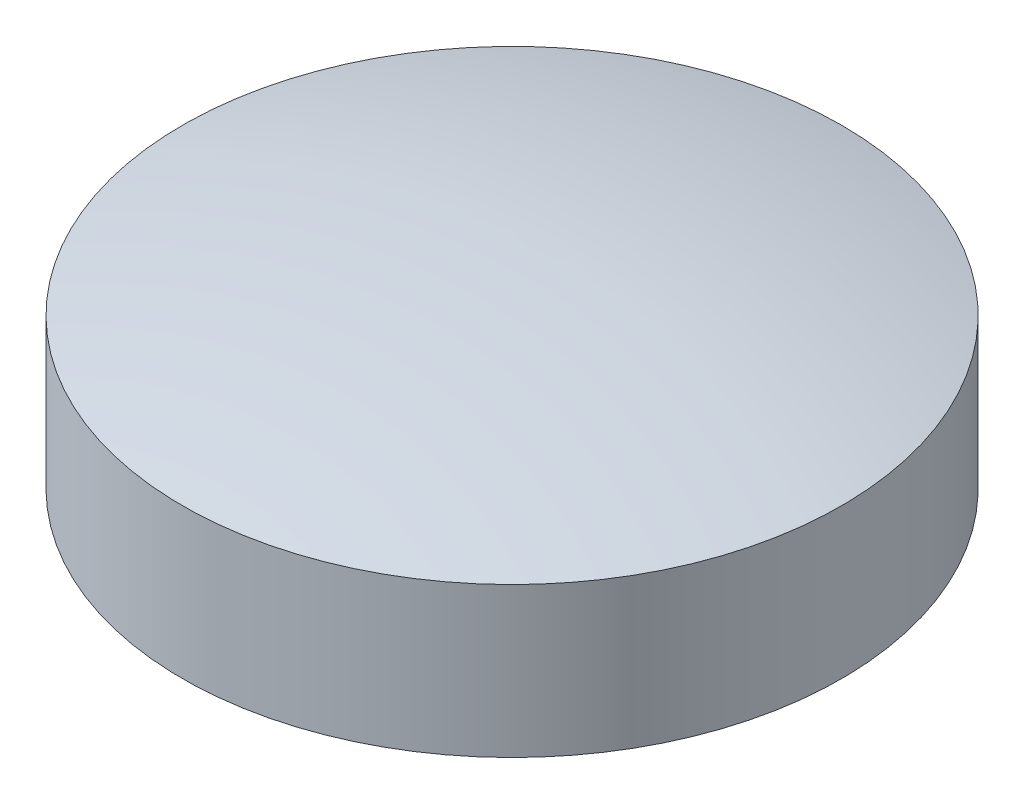
from build123d import *


with BuildPart() as part:
    # Sketch2 → Revolve1 (revolve)
    with BuildSketch(Plane(origin=(0, 0, 0), x_dir=(0, 0, -1), z_dir=(1, 0, 0))):
        with BuildLine():
            Line((0, 0), (22, 0))
            Line((22, 0), (22, 10))
            ThreePointArc((22, 10), (11.101801656, 12.246545474), (0, 13))
            Line((0, 13), (0, 0))
        make_face()
    revolve(axis=Axis((0, 0, 0), (0, 1, 0)))


solid = part.part
